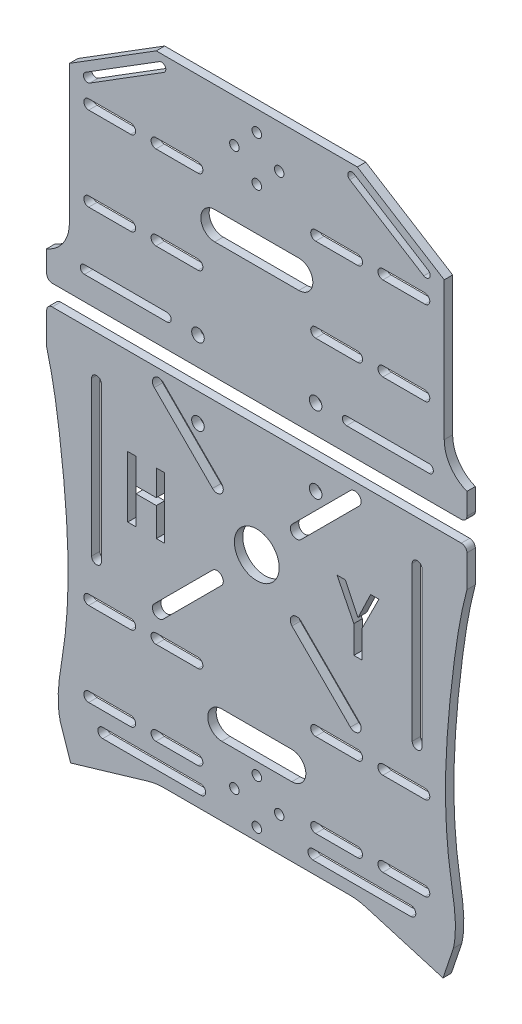
from build123d import *

# Parameters (mm, degrees)
EXTRUDE_1_DEPTH      = 3
SKETCH_7_R           = 2.25
CUT_EXTRUDE_2_DEPTH  = 4.0000001
SKETCH_8_R           = 8
CUT_EXTRUDE_3_DEPTH  = 4.0000001
CUT_EXTRUDE_4_DEPTH  = 3
CUT_EXTRUDE_5_DEPTH  = 3
CUT_EXTRUDE_8_DEPTH  = 3
SKETCH_12_R          = 1.7
CUT_EXTRUDE_9_DEPTH  = 3
SKETCH_13_R          = 1.7
CUT_EXTRUDE_11_DEPTH = 3
CUT_EXTRUDE_12_DEPTH = 4.0000001
FILLET_1_R           = 2
FILLET_2_R           = 2
CUT_EXTRUDE_13_DEPTH = 4.0000001
CUT_EXTRUDE_14_DEPTH = 4.0000001
CUT_EXTRUDE_15_DEPTH = 4.0000001
CUT_EXTRUDE_16_DEPTH = 4.0000001


with BuildPart() as part:
    # 草图1 → 凸台-拉伸1 (new body)
    with BuildSketch(Plane.XY):
        with BuildLine():
            Line((60, 106.603296002), (35.889163634, 121.664519159))
            Line((35.889163634, 121.664519159), (-35.889163634, 121.664519159))
            Line((-35.889163634, 121.664519159), (-60, 106.603296002))
            Line((-60, 106.603296002), (-60, 94.801892265))
            Line((-60, 94.801892265), (-45, 94.801892265))
            ThreePointArc((-45, 94.801892265), (-43.762563133, 94.289329132), (-43.25, 93.051892265))
            Line((-43.25, 93.051892265), (-37.75, 93.051892265))
            ThreePointArc((-37.75, 93.051892265), (-37.237436867, 94.289329132), (-36, 94.801892265))
            Line((-36, 94.801892265), (-21, 94.801892265))
            ThreePointArc((-21, 94.801892265), (-19.762563133, 94.289329132), (-19.25, 93.051892265))
            Line((-19.25, 93.051892265), (19.25, 93.051892265))
            ThreePointArc((19.25, 93.051892265), (19.762563133, 94.289329132), (21, 94.801892265))
            Line((21, 94.801892265), (36, 94.801892265))
            ThreePointArc((36, 94.801892265), (37.237436867, 94.289329132), (37.75, 93.051892265))
            Line((37.75, 93.051892265), (43.25, 93.051892265))
            ThreePointArc((43.25, 93.051892265), (43.762563133, 94.289329132), (45, 94.801892265))
            Line((45, 94.801892265), (60, 94.801892265))
            Line((60, 94.801892265), (60, 106.603296002))
        make_face()
        with BuildLine():
            Line((66.901694095, 102.292041372), (60, 106.603296002))
            Line((60, 106.603296002), (60, 94.801892265))
            ThreePointArc((60, 94.801892265), (61.237436867, 94.289329132), (61.75, 93.051892265))
            Line((61.75, 93.051892265), (66.901694095, 93.051892265))
            Line((66.901694095, 93.051892265), (66.901694095, 102.292041372))
        make_face()
        with BuildLine():
            Line((-60, 94.801892265), (-60, 106.603296002))
            Line((-60, 106.603296002), (-66.901694095, 102.292041372))
            Line((-66.901694095, 102.292041372), (-66.901694095, 93.051892265))
            Line((-66.901694095, 93.051892265), (-61.75, 93.051892265))
            ThreePointArc((-61.75, 93.051892265), (-61.237436867, 94.289329132), (-60, 94.801892265))
        make_face()
        with BuildLine():
            Line((66.901694095, 63.051892265), (66.901694095, 93.051892265))
            Line((66.901694095, 93.051892265), (61.75, 93.051892265))
            ThreePointArc((61.75, 93.051892265), (61.237436867, 91.814455398), (60, 91.301892265))
            Line((60, 91.301892265), (60, 64.801892265))
            ThreePointArc((60, 64.801892265), (61.237436867, 64.289329132), (61.75, 63.051892265))
            Line((61.75, 63.051892265), (66.901694095, 63.051892265))
        make_face()
        with BuildLine():
            Line((-61.75, 93.051892265), (-66.901694095, 93.051892265))
            Line((-66.901694095, 93.051892265), (-66.901694095, 63.051892265))
            Line((-66.901694095, 63.051892265), (-61.75, 63.051892265))
            ThreePointArc((-61.75, 63.051892265), (-61.237436867, 64.289329132), (-60, 64.801892265))
            Line((-60, 64.801892265), (-60, 91.301892265))
            ThreePointArc((-60, 91.301892265), (-61.237436867, 91.814455398), (-61.75, 93.051892265))
        make_face()
        with BuildLine():
            Line((66.901694095, 52.870133869), (66.901694095, 63.051892265))
            Line((66.901694095, 63.051892265), (61.75, 63.051892265))
            ThreePointArc((61.75, 63.051892265), (61.237436867, 61.814455398), (60, 61.301892265))
            Line((60, 61.301892265), (60, 31.261343001))
            Line((60, 31.261343001), (75, 31.261343001))
            Line((75, 31.261343001), (75, 40.933889795))
            ThreePointArc((75, 40.933889795), (69.117351927, 45.658052319), (66.901694095, 52.870133869))
        make_face()
        with BuildLine():
            Line((60, 64.801892265), (60, 91.301892265))
            Line((60, 91.301892265), (45, 91.301892265))
            ThreePointArc((45, 91.301892265), (43.762563133, 91.814455398), (43.25, 93.051892265))
            Line((43.25, 93.051892265), (37.75, 93.051892265))
            ThreePointArc((37.75, 93.051892265), (37.237436867, 91.814455398), (36, 91.301892265))
            Line((36, 91.301892265), (21, 91.301892265))
            ThreePointArc((21, 91.301892265), (19.762563133, 91.814455398), (19.25, 93.051892265))
            Line((19.25, 93.051892265), (-19.25, 93.051892265))
            ThreePointArc((-19.25, 93.051892265), (-19.762563133, 91.814455398), (-21, 91.301892265))
            Line((-21, 91.301892265), (-36, 91.301892265))
            ThreePointArc((-36, 91.301892265), (-37.237436867, 91.814455398), (-37.75, 93.051892265))
            Line((-37.75, 93.051892265), (-43.25, 93.051892265))
            ThreePointArc((-43.25, 93.051892265), (-43.762563133, 91.814455398), (-45, 91.301892265))
            Line((-45, 91.301892265), (-60, 91.301892265))
            Line((-60, 91.301892265), (-60, 64.801892265))
            Line((-60, 64.801892265), (-45, 64.801892265))
            ThreePointArc((-45, 64.801892265), (-43.762563133, 64.289329132), (-43.25, 63.051892265))
            Line((-43.25, 63.051892265), (-37.75, 63.051892265))
            ThreePointArc((-37.75, 63.051892265), (-37.237436867, 64.289329132), (-36, 64.801892265))
            Line((-36, 64.801892265), (-21, 64.801892265))
            ThreePointArc((-21, 64.801892265), (-19.762563133, 64.289329132), (-19.25, 63.051892265))
            Line((-19.25, 63.051892265), (19.25, 63.051892265))
            ThreePointArc((19.25, 63.051892265), (19.762563133, 64.289329132), (21, 64.801892265))
            Line((21, 64.801892265), (36, 64.801892265))
            ThreePointArc((36, 64.801892265), (37.237436867, 64.289329132), (37.75, 63.051892265))
            Line((37.75, 63.051892265), (43.25, 63.051892265))
            ThreePointArc((43.25, 63.051892265), (43.762563133, 64.289329132), (45, 64.801892265))
            Line((45, 64.801892265), (60, 64.801892265))
        make_face()
        with BuildLine():
            Line((-61.75, 63.051892265), (-66.901694095, 63.051892265))
            Line((-66.901694095, 63.051892265), (-66.901694095, 52.870133869))
            ThreePointArc((-66.901694095, 52.870133869), (-69.117351927, 45.658052319), (-75, 40.933889795))
            Line((-75, 40.933889795), (-75, 31.261343001))
            Line((-75, 31.261343001), (-60, 31.261343001))
            Line((-60, 31.261343001), (-60, 61.301892265))
            ThreePointArc((-60, 61.301892265), (-61.237436867, 61.814455398), (-61.75, 63.051892265))
        make_face()
        with BuildLine():
            Line((60, 31.261343001), (60, 61.301892265))
            Line((60, 61.301892265), (45, 61.301892265))
            ThreePointArc((45, 61.301892265), (43.762563133, 61.814455398), (43.25, 63.051892265))
            Line((43.25, 63.051892265), (37.75, 63.051892265))
            ThreePointArc((37.75, 63.051892265), (37.237436867, 61.814455398), (36, 61.301892265))
            Line((36, 61.301892265), (21, 61.301892265))
            ThreePointArc((21, 61.301892265), (19.762563133, 61.814455398), (19.25, 63.051892265))
            Line((19.25, 63.051892265), (-19.25, 63.051892265))
            ThreePointArc((-19.25, 63.051892265), (-19.762563133, 61.814455398), (-21, 61.301892265))
            Line((-21, 61.301892265), (-36, 61.301892265))
            ThreePointArc((-36, 61.301892265), (-37.237436867, 61.814455398), (-37.75, 63.051892265))
            Line((-37.75, 63.051892265), (-43.25, 63.051892265))
            ThreePointArc((-43.25, 63.051892265), (-43.762563133, 61.814455398), (-45, 61.301892265))
            Line((-45, 61.301892265), (-60, 61.301892265))
            Line((-60, 61.301892265), (-60, 31.261343001))
            Line((-60, 31.261343001), (60, 31.261343001))
        make_face()
        with BuildLine():
            Line((60, -58.312864289), (60, 23.940028391))
            Line((60, 23.940028391), (-60, 23.940028391))
            Line((-60, 23.940028391), (-60, -58.312864289))
            Line((-60, -58.312864289), (-45, -58.312864289))
            ThreePointArc((-45, -58.312864289), (-43.25, -60.062864289), (-45, -61.812864289))
            Line((-45, -61.812864289), (-60, -61.812864289))
            Line((-60, -61.812864289), (-60, -88.312864289))
            Line((-60, -88.312864289), (-45, -88.312864289))
            ThreePointArc((-45, -88.312864289), (-43.25, -90.062864289), (-45, -91.812864289))
            Line((-45, -91.812864289), (-60, -91.812864289))
            Line((-60, -91.812864289), (-60, -111.849967256))
            Line((-60, -111.849967256), (-38.845469114, -105.590576733))
            ThreePointArc((-38.845469114, -105.590576733), (-36.037784492, -104.975210108), (-33.17088573, -104.768665882))
            Line((-33.17088573, -104.768665882), (33.17088573, -104.768665882))
            ThreePointArc((33.17088573, -104.768665882), (36.037784492, -104.975210108), (38.845469114, -105.590576733))
            Line((38.845469114, -105.590576733), (60, -111.849967256))
            Line((60, -111.849967256), (60, -91.812864289))
            Line((60, -91.812864289), (45, -91.812864289))
            ThreePointArc((45, -91.812864289), (43.762563133, -91.300301156), (43.25, -90.062864289))
            ThreePointArc((43.25, -90.062864289), (43.762563133, -88.825427422), (45, -88.312864289))
            Line((45, -88.312864289), (60, -88.312864289))
            Line((60, -88.312864289), (60, -61.812864289))
            Line((60, -61.812864289), (45, -61.812864289))
            ThreePointArc((45, -61.812864289), (43.762563133, -61.300301156), (43.25, -60.062864289))
            ThreePointArc((43.25, -60.062864289), (43.762563133, -58.825427422), (45, -58.312864289))
            Line((45, -58.312864289), (60, -58.312864289))
        make_face()
        with BuildLine():
            ThreePointArc((-21, -88.312864289), (-19.762563133, -88.825427422), (-19.25, -90.062864289))
            ThreePointArc((-19.25, -90.062864289), (-19.762563133, -91.300301156), (-21, -91.812864289))
            Line((-21, -91.812864289), (-36, -91.812864289))
            ThreePointArc((-36, -91.812864289), (-37.75, -90.062864289), (-36, -88.312864289))
            Line((-36, -88.312864289), (-21, -88.312864289))
        make_face(mode=Mode.SUBTRACT)
        with BuildLine():
            ThreePointArc((-21, -58.312864289), (-19.762563133, -58.825427422), (-19.25, -60.062864289))
            ThreePointArc((-19.25, -60.062864289), (-19.762563133, -61.300301156), (-21, -61.812864289))
            Line((-21, -61.812864289), (-36, -61.812864289))
            ThreePointArc((-36, -61.812864289), (-37.75, -60.062864289), (-36, -58.312864289))
            Line((-36, -58.312864289), (-21, -58.312864289))
        make_face(mode=Mode.SUBTRACT)
        with BuildLine():
            ThreePointArc((36, -88.312864289), (37.237436867, -88.825427422), (37.75, -90.062864289))
            ThreePointArc((37.75, -90.062864289), (37.237436867, -91.300301156), (36, -91.812864289))
            Line((36, -91.812864289), (21, -91.812864289))
            ThreePointArc((21, -91.812864289), (19.762563133, -91.300301156), (19.25, -90.062864289))
            ThreePointArc((19.25, -90.062864289), (19.762563133, -88.825427422), (21, -88.312864289))
            Line((21, -88.312864289), (36, -88.312864289))
        make_face(mode=Mode.SUBTRACT)
        with BuildLine():
            ThreePointArc((36, -58.312864289), (37.237436867, -58.825427422), (37.75, -60.062864289))
            ThreePointArc((37.75, -60.062864289), (37.237436867, -61.300301156), (36, -61.812864289))
            Line((36, -61.812864289), (21, -61.812864289))
            ThreePointArc((21, -61.812864289), (19.762563133, -61.300301156), (19.25, -60.062864289))
            ThreePointArc((19.25, -60.062864289), (19.762563133, -58.825427422), (21, -58.312864289))
            Line((21, -58.312864289), (36, -58.312864289))
        make_face(mode=Mode.SUBTRACT)
        with BuildLine():
            Line((75, 23.940028391), (60, 23.940028391))
            Line((60, 23.940028391), (60, -58.312864289))
            ThreePointArc((60, -58.312864289), (61.237436867, -58.825427422), (61.75, -60.062864289))
            Line((61.75, -60.062864289), (67.402721334, -60.062864289))
            add(Edge.make_bspline(
                [(75, 10.562559835), (72.695878257, 1.907314233), (70.339582535, -13.372796253), (67.818206704, -36.939032951), (67.208860388, -51.77269444), (67.402721334, -60.062864289)],
                knots=[0, 0, 0, 0, 0.235246678, 0.40629419, 0.624108181, 0.624108181, 0.624108181, 0.624108181], degree=3))
            Line((75, 10.562559835), (75, 23.940028391))
        make_face()
        with BuildLine():
            Line((-60, -58.312864289), (-60, 23.940028391))
            Line((-60, 23.940028391), (-75, 23.940028391))
            Line((-75, 23.940028391), (-75, 10.562559835))
            add(Edge.make_bspline(
                [(-75, 10.562559835), (-72.695878257, 1.907314233), (-70.339582535, -13.372796253), (-67.818206704, -36.939032951), (-67.208860388, -51.77269444), (-67.402721334, -60.062864289)],
                knots=[0, 0, 0, 0, 0.235246678, 0.40629419, 0.624108181, 0.624108181, 0.624108181, 0.624108181], degree=3))
            add(Edge.make_bspline(
                [(-67.402721334, -60.062864289), (-67.560325872, -66.802583754), (-68.323504015, -76.843670093), (-70.154131955, -86.778530076), (-70.533712858, -90.062864289)],
                knots=[0.624108181, 0.624108181, 0.624108181, 0.624108181, 0.801186001, 0.888408652, 0.888408652, 0.888408652, 0.888408652], degree=3))
            add(Edge.make_bspline(
                [(-70.533712858, -90.062864289), (-71.019342956, -94.264792095), (-71.137422935, -98.476048206), (-70.1742624, -102.732794059)],
                knots=[0.888408652, 0.888408652, 0.888408652, 0.888408652, 1, 1, 1, 1], degree=3))
            Line((-70.1742624, -102.732794059), (-66.460817635, -113.761651372))
            Line((-66.460817635, -113.761651372), (-60, -111.849967256))
            Line((-60, -111.849967256), (-60, -91.812864289))
            ThreePointArc((-60, -91.812864289), (-61.75, -90.062864289), (-60, -88.312864289))
            Line((-60, -88.312864289), (-60, -61.812864289))
            ThreePointArc((-60, -61.812864289), (-61.75, -60.062864289), (-60, -58.312864289))
        make_face()
        with BuildLine():
            Line((67.402721334, -60.062864289), (61.75, -60.062864289))
            ThreePointArc((61.75, -60.062864289), (61.237436867, -61.300301156), (60, -61.812864289))
            Line((60, -61.812864289), (60, -88.312864289))
            ThreePointArc((60, -88.312864289), (61.237436867, -88.825427422), (61.75, -90.062864289))
            Line((61.75, -90.062864289), (70.533712858, -90.062864289))
            add(Edge.make_bspline(
                [(67.402721334, -60.062864289), (67.560325872, -66.802583754), (68.323504015, -76.843670093), (70.154131955, -86.778530076), (70.533712858, -90.062864289)],
                knots=[0.624108181, 0.624108181, 0.624108181, 0.624108181, 0.801186001, 0.888408652, 0.888408652, 0.888408652, 0.888408652], degree=3))
        make_face()
        with BuildLine():
            add(Edge.make_bspline(
                [(70.533712858, -90.062864289), (71.019342956, -94.264792095), (71.137422935, -98.476048206), (70.1742624, -102.732794059)],
                knots=[0.888408652, 0.888408652, 0.888408652, 0.888408652, 1, 1, 1, 1], degree=3))
            Line((70.533712858, -90.062864289), (61.75, -90.062864289))
            ThreePointArc((61.75, -90.062864289), (61.237436867, -91.300301156), (60, -91.812864289))
            Line((60, -91.812864289), (60, -111.849967256))
            Line((60, -111.849967256), (66.460817635, -113.761651372))
            Line((66.460817635, -113.761651372), (70.1742624, -102.732794059))
        make_face()
    extrude(amount=EXTRUDE_1_DEPTH)

    # 草图7 → 切除-拉伸2 (cut, through all)
    with BuildSketch(Plane(origin=(0, 0, 0), x_dir=(-1, 0, 0), z_dir=(0, 0, -1))):
        with Locations((-21, 41.261343001)):
            Circle(SKETCH_7_R)
        with Locations((21, 41.261343001)):
            Circle(SKETCH_7_R)
        with Locations((-21, 13.940028391)):
            Circle(SKETCH_7_R)
        with Locations((21, 13.940028391)):
            Circle(SKETCH_7_R)
    extrude(amount=-CUT_EXTRUDE_2_DEPTH, mode=Mode.SUBTRACT)

    # 草图8 → 切除-拉伸3 (cut, through all)
    with BuildSketch(Plane.XY.offset(3)):
        with BuildLine():
            Line((-12.621438714, -0.378557945), (-33.409010345, 20.409013685))
            ThreePointArc((-33.409010345, 20.409013685), (-36.590999434, 20.409013643), (-36.590999309, 17.227024553))
            Line((-36.590999309, 17.227024553), (-15.803426586, -3.560545984))
            ThreePointArc((-15.803426586, -3.560545984), (-12.621438673, -3.560545859), (-12.621438714, -0.378557945))
        make_face()
        with BuildLine():
            Line((33.410462056, 20.410458798), (12.572988319, -0.427010824))
            ThreePointArc((12.572988319, -0.427010824), (12.644570441, -3.584764993), (15.803045702, -3.56090242))
            Line((15.803045702, -3.56090242), (34.999999982, 15.636052774))
            Line((34.999999982, 15.636052774), (36.588086952, 17.224139819))
            ThreePointArc((36.588086952, 17.224139819), (36.592433993, 20.406111757), (33.410462056, 20.410458798))
        make_face()
        with BuildLine():
            Line((-15.803784812, -28.80377835), (-36.591002186, -49.590991619))
            ThreePointArc((-36.591002186, -49.590991619), (-36.591002403, -52.772972232), (-33.40902179, -52.772972254))
            Line((-33.40902179, -52.772972254), (-12.573723916, -31.937673388))
            ThreePointArc((-12.573723916, -31.937673388), (-12.64530628, -28.779915954), (-15.803784812, -28.80377835))
        make_face()
        with BuildLine():
            Line((36.590992666, -49.590989326), (15.803414627, -28.803411286))
            ThreePointArc((15.803414627, -28.803411286), (12.654338964, -28.769774302), (12.55344336, -31.917412949))
            Line((12.55344336, -31.917412949), (33.409007381, -52.772974779))
            ThreePointArc((33.409007381, -52.772974779), (36.590992708, -52.772974653), (36.590992666, -49.590989326))
        make_face()
        with Locations((-0.000368782, -16.182341354)):
            Circle(SKETCH_8_R)
    extrude(amount=-CUT_EXTRUDE_3_DEPTH, mode=Mode.SUBTRACT)

    # 草图9 → 切除-拉伸4 (cut)
    with BuildSketch(Plane.XY.offset(3)):
        with BuildLine():
            Line((55, -100.49704609), (20, -100.49704609))
            ThreePointArc((20, -100.49704609), (18.25, -98.74704609), (20, -96.99704609))
            Line((20, -96.99704609), (55, -96.99704609))
            ThreePointArc((55, -96.99704609), (56.75, -98.74704609), (55, -100.49704609))
        make_face()
        with BuildLine():
            Line((-55, -96.99704609), (-20, -96.99704609))
            ThreePointArc((-20, -96.99704609), (-18.25, -98.74704609), (-20, -100.49704609))
            Line((-20, -100.49704609), (-55, -100.49704609))
            ThreePointArc((-55, -100.49704609), (-56.75, -98.74704609), (-55, -96.99704609))
        make_face()
    extrude(amount=-CUT_EXTRUDE_4_DEPTH, mode=Mode.SUBTRACT)

    # 草图10 → 切除-拉伸5 (cut)
    with BuildSketch(Plane.XY.offset(3)):
        with BuildLine():
            Line((12.5, -80.062864289), (-12.5, -80.062864289))
            ThreePointArc((-12.5, -80.062864289), (-17.5, -75.062864289), (-12.5, -70.062864289))
            Line((-12.5, -70.062864289), (12.5, -70.062864289))
            ThreePointArc((12.5, -70.062864289), (17.5, -75.062864289), (12.5, -80.062864289))
        make_face()
    extrude(amount=-CUT_EXTRUDE_5_DEPTH, mode=Mode.SUBTRACT)

    # 草图11 → 切除-拉伸8 (cut)
    with BuildSketch(Plane.XY.offset(3)):
        with BuildLine():
            Line((15, 73.051892265), (-15, 73.051892265))
            ThreePointArc((-15, 73.051892265), (-20, 78.051892265), (-15, 83.051892265))
            Line((-15, 83.051892265), (15, 83.051892265))
            ThreePointArc((15, 83.051892265), (20, 78.051892265), (15, 73.051892265))
        make_face()
    extrude(amount=-CUT_EXTRUDE_8_DEPTH, mode=Mode.SUBTRACT)

    # 草图12 → 切除-拉伸9 (cut)
    with BuildSketch(Plane.XY.offset(3)):
        with Locations((0, 114.371786435)):
            Circle(SKETCH_12_R)
        with Locations((0, 98.371786435)):
            Circle(SKETCH_12_R)
        with Locations((8, 106.371786435)):
            Circle(SKETCH_12_R)
        with Locations((-8, 106.371786435)):
            Circle(SKETCH_12_R)
    extrude(amount=-CUT_EXTRUDE_9_DEPTH, mode=Mode.SUBTRACT)

    # 草图13 → 切除-拉伸11 (cut)
    with BuildSketch(Plane.XY.offset(3)):
        with Locations((0, -84.415765086)):
            Circle(SKETCH_13_R)
        with Locations((8, -92.415765086)):
            Circle(SKETCH_13_R)
        with Locations((0, -100.415765086)):
            Circle(SKETCH_13_R)
        with Locations((-8, -92.415765086)):
            Circle(SKETCH_13_R)
    extrude(amount=-CUT_EXTRUDE_11_DEPTH, mode=Mode.SUBTRACT)

    # 草图14 → 切除-拉伸12 (cut, through all)
    with BuildSketch(Plane.XY.offset(3)):
        with BuildLine():
            Line((-55.475501567, 8.919687236), (-55.475501567, -46.080312764))
            ThreePointArc((-55.475501567, -46.080312764), (-57.225501567, -47.830312764), (-58.975501567, -46.080312764))
            Line((-58.975501567, -46.080312764), (-58.975501567, 8.919687236))
            ThreePointArc((-58.975501567, 8.919687236), (-57.225501567, 10.669687236), (-55.475501567, 8.919687236))
        make_face()
        with BuildLine():
            Line((58.975501567, 8.919687236), (58.975501567, -46.080312764))
            ThreePointArc((58.975501567, -46.080312764), (57.225501567, -47.830312764), (55.475501567, -46.080312764))
            Line((55.475501567, -46.080312764), (55.475501567, 8.919687236))
            ThreePointArc((55.475501567, 8.919687236), (57.225501567, 10.669687236), (58.975501567, 8.919687236))
        make_face()
    extrude(amount=-CUT_EXTRUDE_12_DEPTH, mode=Mode.SUBTRACT)

    # 圆角1
    fillet_1_edges = [part.edges().sort_by_distance(p)[0] for p in [
        (75, 31.261343001, 1.5),
        (-75, 31.261343001, 1.5),
    ]]
    fillet(fillet_1_edges, radius=FILLET_1_R)

    # 圆角2
    fillet_2_edges = [part.edges().sort_by_distance(p)[0] for p in [
        (-75, 23.940028391, 1.5),
        (75, 23.940028391, 1.5),
    ]]
    fillet(fillet_2_edges, radius=FILLET_2_R)

    # 草图15 → 切除-拉伸13 (cut, through all)
    with BuildSketch(Plane(origin=(0, 0, 0), x_dir=(-1, 0, 0), z_dir=(0, 0, -1))):
        with BuildLine():
            Line((-61.184216401, 102.403501276), (-34.774762862, 118.900592756))
            ThreePointArc((-34.774762862, 118.900592756), (-32.70788159, 118.423097411), (-33.185376934, 116.356216138))
            Line((-33.185376934, 116.356216138), (-59.594830473, 99.859124658))
            ThreePointArc((-59.594830473, 99.859124658), (-61.661711746, 100.336620003), (-61.184216401, 102.403501276))
        make_face()
        with BuildLine():
            Line((59.594830473, 99.859124658), (33.185376934, 116.356216138))
            ThreePointArc((33.185376934, 116.356216138), (32.70788159, 118.423097411), (34.774762862, 118.900592756))
            Line((34.774762862, 118.900592756), (61.184216401, 102.403501276))
            ThreePointArc((61.184216401, 102.403501276), (61.661711746, 100.336620003), (59.594830473, 99.859124658))
        make_face()
    extrude(amount=-CUT_EXTRUDE_13_DEPTH, mode=Mode.SUBTRACT)

    # 草图16 → 切除-拉伸14 (cut, through all)
    with BuildSketch(Plane(origin=(0, 0, 0), x_dir=(-1, 0, 0), z_dir=(0, 0, -1))):
        with BuildLine():
            Line((-61.516979467, 42.761343001), (-32.056291893, 42.761343001))
            ThreePointArc((-32.056291893, 42.761343001), (-30.556291893, 41.261343001), (-32.056291893, 39.761343001))
            Line((-32.056291893, 39.761343001), (-61.516979467, 39.761343001))
            ThreePointArc((-61.516979467, 39.761343001), (-63.016979467, 41.261343001), (-61.516979467, 42.761343001))
        make_face()
        with BuildLine():
            Line((61.516979467, 39.761343001), (32.056291893, 39.761343001))
            ThreePointArc((32.056291893, 39.761343001), (30.556291893, 41.261343001), (32.056291893, 42.761343001))
            Line((32.056291893, 42.761343001), (61.516979467, 42.761343001))
            ThreePointArc((61.516979467, 42.761343001), (63.016979467, 41.261343001), (61.516979467, 39.761343001))
        make_face()
    extrude(amount=-CUT_EXTRUDE_14_DEPTH, mode=Mode.SUBTRACT)

    # 草图17 → 切除-拉伸15 (cut, through all)
    with BuildSketch(Plane(origin=(0, 0, 0), x_dir=(-1, 0, 0), z_dir=(0, 0, -1))):
        Polygon((-28.645414283, -8.118433382), (-34.644957411, -20.11751964), (-34.644957411, -29.946558382), (-37.580904049, -29.946558382), (-37.580904049, -20.11751964), (-43.580447177, -8.118433382), (-40.64450054, -8.118433382), (-36.176755657, -17.43687271), (-36.049105803, -17.43687271), (-31.58136092, -8.118433382), align=None)
    extrude(amount=-CUT_EXTRUDE_15_DEPTH, mode=Mode.SUBTRACT)

    # 草图18 → 切除-拉伸16 (cut, through all)
    with BuildSketch(Plane(origin=(0, 0, 0), x_dir=(-1, 0, 0), z_dir=(0, 0, -1))):
        Polygon((46.06697123, -29.087529791), (43.131024593, -29.087529791), (43.131024593, -18.875541487), (35.854982926, -18.875541487), (35.854982926, -29.087529791), (32.919036289, -29.087529791), (32.919036289, -7.259404791), (35.854982926, -7.259404791), (35.854982926, -16.450194265), (43.131024593, -16.450194265), (43.131024593, -7.259404791), (46.06697123, -7.259404791), align=None)
    extrude(amount=-CUT_EXTRUDE_16_DEPTH, mode=Mode.SUBTRACT)


solid = part.part
